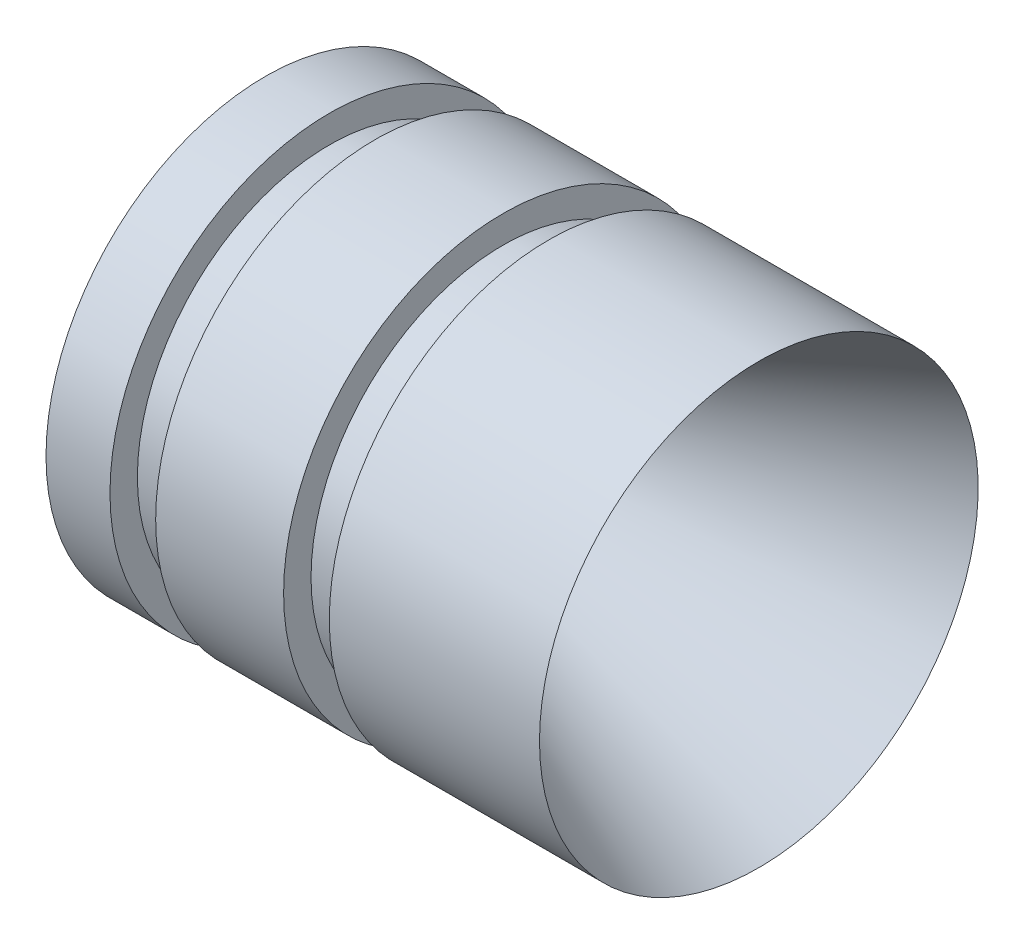
from build123d import *

# Parameters (mm, degrees)
FILLET2_R = 2


with BuildPart() as part:
    # Sketch1 → Revolve1 (revolve)
    with BuildSketch(Plane(origin=(0, 0, 0), x_dir=(1, 0, 0), z_dir=(0, 1, 0))):
        Polygon((-4.577566402, 5.987981991), (-1.077566402, 5.987981991), (-1.077566402, 4.487981991), (1.422433598, 4.487981991), (1.422433598, 5.987981991), (8.422433598, 5.987981991), (8.422433598, 4.487981991), (10.922433598, 4.487981991), (10.922433598, 5.987981991), (22.422433598, 5.987981991), (7.422433598, -0.762018009), (2.422433598, -0.762018009), align=None)
    revolve(axis=Axis((-4.577566402, 0, 6.012018009), (1, 0, 0)))

    # Fillet2
    fillet2_edges = [part.edges().sort_by_distance(p)[0] for p in [
        (7.422433598, 0, 11.262018009),
        (2.422433598, 0, 11.262018009),
    ]]
    fillet(fillet2_edges, radius=FILLET2_R)


solid = part.part
